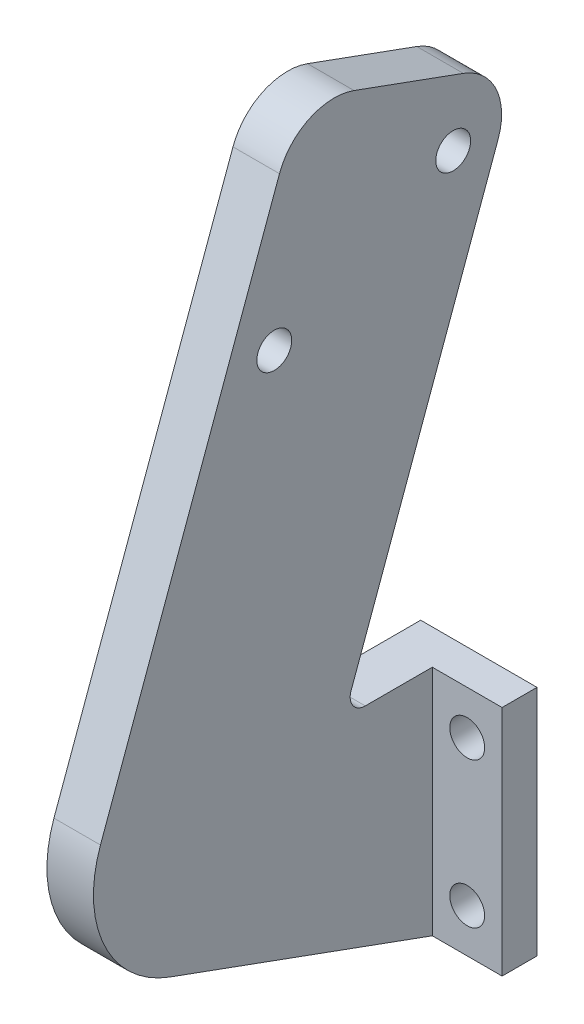
from build123d import *

# Parameters (mm, degrees)
SKETCH_1_W          = 17
SKETCH_1_H          = 20
SKETCH_1_R          = 1.5
EXTRUDE_1_DEPTH     = 3
EXTRUDE_2_DEPTH     = 5
SKETCH_4_R          = 1.5
CUT_EXTRUDE_1_DEPTH = 5
FILLET_2_R          = 5
FILLET_3_R          = 1.3
FILLET_4_R          = 10
SKETCH_5_W          = 6
SKETCH_5_H          = 20
CUT_EXTRUDE_2_DEPTH = 10
SKETCH_6_R          = 1.5
CUT_EXTRUDE_3_DEPTH = 1


with BuildPart() as part:
    # 草图1 → 凸台-拉伸1 (new body)
    with BuildSketch(Plane.XY):
        with Locations((8.5, 10)):
            Rectangle(SKETCH_1_W, SKETCH_1_H)
        with Locations((3, 16.25)):
            Circle(SKETCH_1_R, mode=Mode.SUBTRACT)
        with Locations((14, 16.25)):
            Circle(SKETCH_1_R, mode=Mode.SUBTRACT)
        with Locations((14, 3.75)):
            Circle(SKETCH_1_R, mode=Mode.SUBTRACT)
        with Locations((3, 3.75)):
            Circle(SKETCH_1_R, mode=Mode.SUBTRACT)
    extrude(amount=EXTRUDE_1_DEPTH)

    # 草图3 → 凸台-拉伸2 (add)
    with BuildSketch(Plane.ZY.offset(-6)):
        Polygon((3, 20), (10.619084129, 20), (-4.365511909, 61.169839254), (14.428340507, 68.01024212), (34.949549107, 11.628684873), (3, 0), align=None)
    extrude(amount=-EXTRUDE_2_DEPTH)

    # 草图4 → 切除-拉伸1 (cut)
    with BuildSketch(Plane(origin=(11, 0, 0), x_dir=(0, 0, -1), z_dir=(1, 0, 0))):
        with Locations((-16.586518504, 50.385479207)):
            Circle(SKETCH_4_R)
        with Locations((-1.205965334, 57.557548937)):
            Circle(SKETCH_4_R)
    extrude(amount=-CUT_EXTRUDE_1_DEPTH, mode=Mode.SUBTRACT)

    # 圆角2
    fillet_2_edges = [part.edges().sort_by_distance(p)[0] for p in [
        (8.5, 61.169839254, -4.365511909),
        (8.5, 68.01024212, 14.428340507),
    ]]
    fillet(fillet_2_edges, radius=FILLET_2_R)

    # 圆角3
    fillet_3_edges = [part.edges().sort_by_distance(p)[0] for p in [
        (8.5, 20, 10.619084129),
    ]]
    fillet(fillet_3_edges, radius=FILLET_3_R)

    # 圆角4
    fillet_4_edges = [part.edges().sort_by_distance(p)[0] for p in [
        (8.5, 11.628684873, 34.949549107),
    ]]
    fillet(fillet_4_edges, radius=FILLET_4_R)

    # 草图5 → 切除-拉伸2 (cut)
    with BuildSketch(Plane.XY.offset(3)):
        with Locations((3, 10)):
            Rectangle(SKETCH_5_W, SKETCH_5_H)
    extrude(amount=-CUT_EXTRUDE_2_DEPTH, mode=Mode.SUBTRACT)

    # 草图6 → 切除-拉伸3 (cut)
    with BuildSketch(Plane.ZY.offset(-6)):
        with BuildLine():
            Line((3, 0), (25.552622899, 8.20848344))
            ThreePointArc((25.552622899, 8.20848344), (31.195499336, 13.37922703), (31.529347673, 21.025611081))
            Line((31.529347673, 21.025611081), (16.138441224, 63.311779016))
            ThreePointArc((16.138441224, 63.311779016), (13.553069429, 66.133217235), (9.729877403, 66.300141404))
            Line((9.729877403, 66.300141404), (0.332951195, 62.87993997))
            ThreePointArc((0.332951195, 62.87993997), (-2.488487023, 60.294568175), (-2.655411192, 56.47137615))
            Line((-2.655411192, 56.47137615), (9.984092128, 21.744626186))
            ThreePointArc((9.984092128, 21.744626186), (9.827389378, 20.554350633), (8.762491721, 20))
            Line((8.762491721, 20), (0, 20))
            Line((0, 20), (0, 0))
            Line((0, 0), (3, 0))
        make_face()
        with Locations((16.586518504, 50.385479207)):
            Circle(SKETCH_6_R, mode=Mode.SUBTRACT)
        with Locations((1.205965334, 57.557548937)):
            Circle(SKETCH_6_R, mode=Mode.SUBTRACT)
    extrude(amount=-CUT_EXTRUDE_3_DEPTH, mode=Mode.SUBTRACT)


solid = part.part
